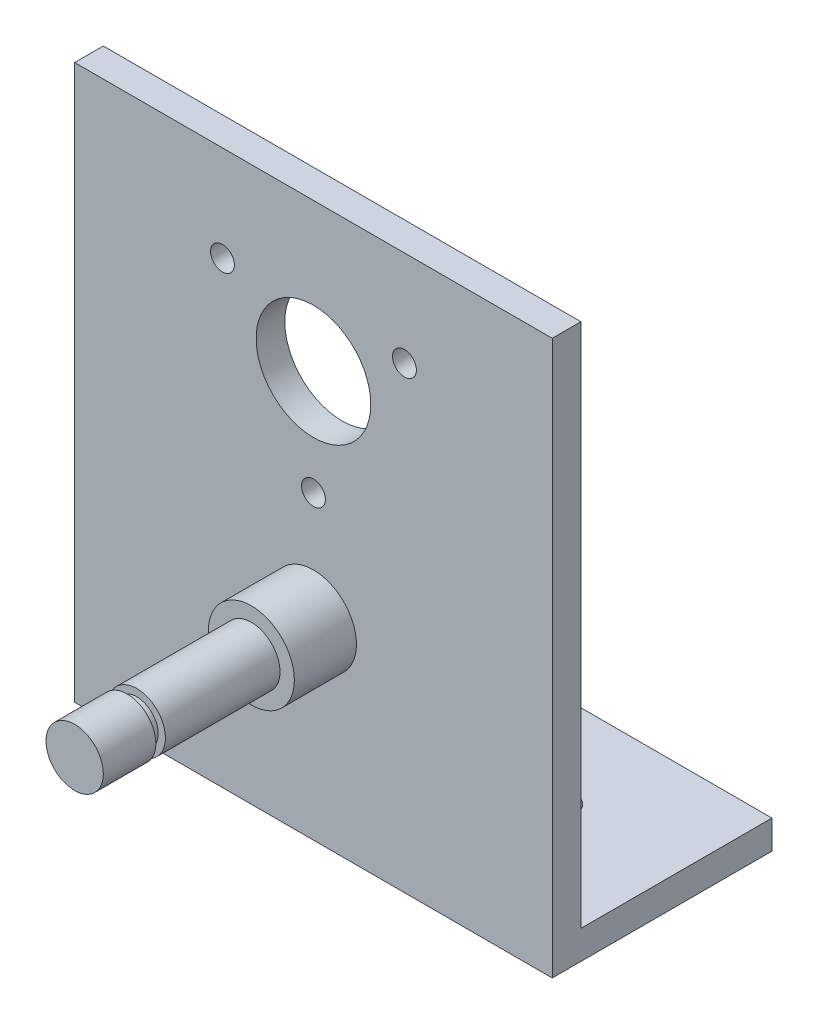
from build123d import *

# Parameters (mm, degrees)
SKETCH1_W           = 50
SKETCH1_H           = 58
BOSS_EXTRUDE1_DEPTH = 3
SKETCH2_W           = 50
SKETCH2_H           = 3
BOSS_EXTRUDE2_DEPTH = 20
SKETCH6_R           = 3
BOSS_EXTRUDE3_DEPTH = 25
SKETCH7_R           = 6
CUT_EXTRUDE2_DEPTH  = 24
SKETCH9_R           = 1.9
CUT_EXTRUDE3_DEPTH  = 4
SKETCH10_R          = 1.25
CUT_EXTRUDE4_DEPTH  = 10
BOSS_EXTRUDE4_REACH = 31.5
SKETCH11_R          = 4.5
SKETCH12_R          = 3
SKETCH12_R_2        = 2.25
CUT_EXTRUDE5_DEPTH  = 1


with BuildPart() as part:
    # Sketch1 → Boss-Extrude1 (new body)
    with BuildSketch(Plane.XY):
        with Locations((-30.619684785, 7.512687188)):
            Rectangle(SKETCH1_W, SKETCH1_H)
    extrude(amount=BOSS_EXTRUDE1_DEPTH)

    # Sketch2 → Boss-Extrude2 (add)
    with BuildSketch(Plane(origin=(0, 0, 0), x_dir=(-1, 0, 0), z_dir=(0, 0, -1))):
        with Locations((30.619684785, -19.987312812)):
            Rectangle(SKETCH2_W, SKETCH2_H)
    extrude(amount=BOSS_EXTRUDE2_DEPTH)

    # Sketch6 → Boss-Extrude3 (add)
    with BuildSketch(Plane.XY.offset(3)):
        with Locations((-30.619684785, -1.487312812)):
            Circle(SKETCH6_R)
    extrude(amount=BOSS_EXTRUDE3_DEPTH)

    # Sketch7 → Cut-Extrude2 (cut, through all)
    with BuildSketch(Plane.XY.offset(3)):
        with Locations((-30.619684785, 21.012687188)):
            Circle(SKETCH7_R)
    extrude(amount=-CUT_EXTRUDE2_DEPTH, mode=Mode.SUBTRACT)

    # Sketch9 → Cut-Extrude3 (cut, through all)
    with BuildSketch(Plane(origin=(0, -18.487312812, 0), x_dir=(1, 0, 0), z_dir=(0, 1, 0))):
        with Locations((-18.119684785, 10)):
            Circle(SKETCH9_R)
        with Locations((-43.119684785, 10)):
            Circle(SKETCH9_R)
    extrude(amount=-CUT_EXTRUDE3_DEPTH, mode=Mode.SUBTRACT)

    # Sketch10 → Cut-Extrude4 (cut)
    with BuildSketch(Plane.XY.offset(3)):
        with Locations((-40.145964226, 26.512687188)):
            Circle(SKETCH10_R)
        with Locations((-21.093405343, 26.512687188)):
            Circle(SKETCH10_R)
        with Locations((-30.619684785, 10.012687188)):
            Circle(SKETCH10_R)
    extrude(amount=-CUT_EXTRUDE4_DEPTH, mode=Mode.SUBTRACT)

    # Sketch11 → Boss-Extrude4 (add, up to next)
    with BuildSketch(Plane.XY.offset(9.5), mode=Mode.PRIVATE) as boss_extrude4_sk1:
        with Locations((-30.619684785, -1.487312812)):
            Circle(SKETCH11_R)
    boss_extrude4_tool1 = extrude(boss_extrude4_sk1.sketch, amount=-BOSS_EXTRUDE4_REACH, mode=Mode.PRIVATE) - part.part
    add(boss_extrude4_tool1.solids().sort_by_distance((-30.619685, -1.487313, 9.5))[0])

    # Sketch12 → Cut-Extrude5 (cut)
    with BuildSketch(Plane.XY.offset(21.5)):
        with Locations((-30.619684785, -1.487312812)):
            Circle(SKETCH12_R)
        with Locations((-30.619684785, -1.487312812)):
            Circle(SKETCH12_R_2, mode=Mode.SUBTRACT)
    extrude(amount=CUT_EXTRUDE5_DEPTH, mode=Mode.SUBTRACT)


solid = part.part
